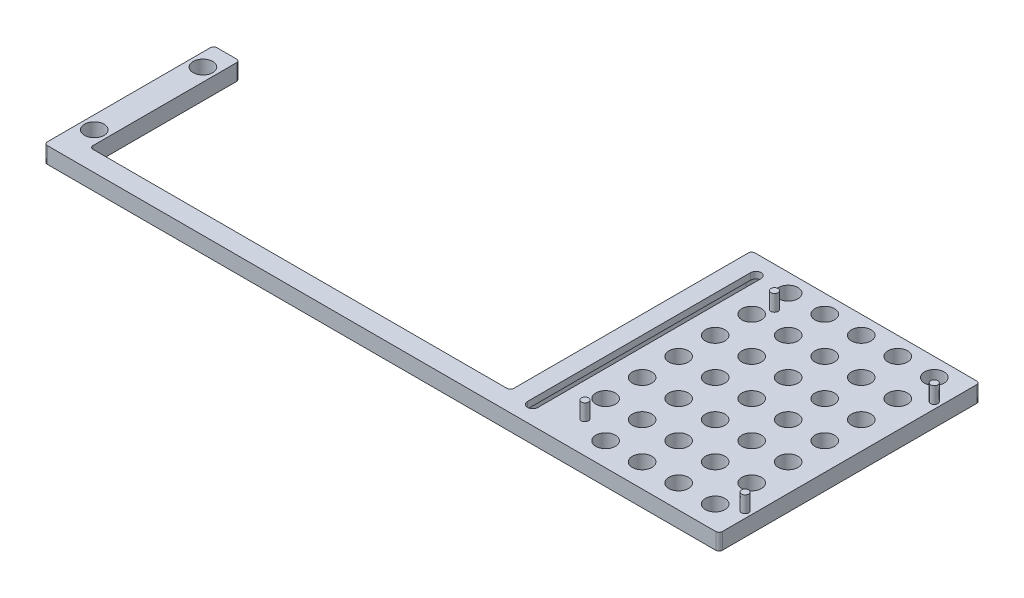
from build123d import *

# Parameters (mm, degrees)
SKETCH1_R           = 3
BOSS_EXTRUDE2_DEPTH = 5
SKETCH2_R           = 1.1
BOSS_EXTRUDE3_DEPTH = 5
FILLET1_R           = 1
CUT_EXTRUDE1_DEPTH  = 3


with BuildPart() as part:
    # Sketch1 → Boss-Extrude2 (new body)
    with BuildSketch(Plane(origin=(0, 0, 0), x_dir=(1, 0, 0), z_dir=(0, 1, 0))):
        Polygon((-35, 40), (35, 40), (35, -40), (-35, -40), (-172, -40), (-172, -34), (-172, 12), (-164, 12), (-164, -34), (-35, -34), align=None)
        with Locations((-18.2, 34.4)):
            Circle(SKETCH1_R, mode=Mode.SUBTRACT)
        with Locations((-7, 34.4)):
            Circle(SKETCH1_R, mode=Mode.SUBTRACT)
        with Locations((4.2, 34.4)):
            Circle(SKETCH1_R, mode=Mode.SUBTRACT)
        with Locations((15.4, 34.4)):
            Circle(SKETCH1_R, mode=Mode.SUBTRACT)
        with Locations((26.6, 34.4)):
            Circle(SKETCH1_R, mode=Mode.SUBTRACT)
        with Locations((-18.2, 23.2)):
            Circle(SKETCH1_R, mode=Mode.SUBTRACT)
        with Locations((-7, 23.2)):
            Circle(SKETCH1_R, mode=Mode.SUBTRACT)
        with Locations((4.2, 23.2)):
            Circle(SKETCH1_R, mode=Mode.SUBTRACT)
        with Locations((15.4, 23.2)):
            Circle(SKETCH1_R, mode=Mode.SUBTRACT)
        with Locations((26.6, 23.2)):
            Circle(SKETCH1_R, mode=Mode.SUBTRACT)
        with Locations((-18.2, 12)):
            Circle(SKETCH1_R, mode=Mode.SUBTRACT)
        with Locations((-7, 12)):
            Circle(SKETCH1_R, mode=Mode.SUBTRACT)
        with Locations((4.2, 12)):
            Circle(SKETCH1_R, mode=Mode.SUBTRACT)
        with Locations((15.4, 12)):
            Circle(SKETCH1_R, mode=Mode.SUBTRACT)
        with Locations((26.6, 12)):
            Circle(SKETCH1_R, mode=Mode.SUBTRACT)
        with Locations((-18.2, 0.8)):
            Circle(SKETCH1_R, mode=Mode.SUBTRACT)
        with Locations((-7, 0.8)):
            Circle(SKETCH1_R, mode=Mode.SUBTRACT)
        with Locations((4.2, 0.8)):
            Circle(SKETCH1_R, mode=Mode.SUBTRACT)
        with Locations((15.4, 0.8)):
            Circle(SKETCH1_R, mode=Mode.SUBTRACT)
        with Locations((26.6, 0.8)):
            Circle(SKETCH1_R, mode=Mode.SUBTRACT)
        with Locations((-18.2, -10.4)):
            Circle(SKETCH1_R, mode=Mode.SUBTRACT)
        with Locations((-7, -10.4)):
            Circle(SKETCH1_R, mode=Mode.SUBTRACT)
        with Locations((4.2, -10.4)):
            Circle(SKETCH1_R, mode=Mode.SUBTRACT)
        with Locations((15.4, -10.4)):
            Circle(SKETCH1_R, mode=Mode.SUBTRACT)
        with Locations((26.6, -10.4)):
            Circle(SKETCH1_R, mode=Mode.SUBTRACT)
        with Locations((-18.2, -21.6)):
            Circle(SKETCH1_R, mode=Mode.SUBTRACT)
        with Locations((-7, -21.6)):
            Circle(SKETCH1_R, mode=Mode.SUBTRACT)
        with Locations((4.2, -21.6)):
            Circle(SKETCH1_R, mode=Mode.SUBTRACT)
        with Locations((15.4, -21.6)):
            Circle(SKETCH1_R, mode=Mode.SUBTRACT)
        with Locations((26.6, -21.6)):
            Circle(SKETCH1_R, mode=Mode.SUBTRACT)
        with Locations((-7, -32.8)):
            Circle(SKETCH1_R, mode=Mode.SUBTRACT)
        with Locations((4.2, -32.8)):
            Circle(SKETCH1_R, mode=Mode.SUBTRACT)
        with Locations((15.4, -32.8)):
            Circle(SKETCH1_R, mode=Mode.SUBTRACT)
        with Locations((26.6, -32.8)):
            Circle(SKETCH1_R, mode=Mode.SUBTRACT)
        with Locations((-168, 4.718835642)):
            Circle(SKETCH1_R, mode=Mode.SUBTRACT)
        with Locations((-168, -28.604223743)):
            Circle(SKETCH1_R, mode=Mode.SUBTRACT)
        with BuildLine():
            Line((-26.219397272, 34.096793065), (-26.219397272, -34.303206935))
            ThreePointArc((-26.219397272, -34.303206935), (-27.819397272, -35.903206935), (-29.419397272, -34.303206935))
            Line((-29.419397272, -34.303206935), (-29.419397272, 34.096793065))
            ThreePointArc((-29.419397272, 34.096793065), (-27.819397272, 35.696793065), (-26.219397272, 34.096793065))
        make_face(mode=Mode.SUBTRACT)
    extrude(amount=BOSS_EXTRUDE2_DEPTH)

    # Sketch2 → Boss-Extrude3 (add)
    with BuildSketch(Plane(origin=(0, 5, 0), x_dir=(1, 0, 0), z_dir=(0, 1, 0))):
        with Locations((33, -30)):
            Circle(SKETCH2_R)
        with Locations((-15.999841725, -30.124542974)):
            Circle(SKETCH2_R)
        with Locations((-15.999841725, 28)):
            Circle(SKETCH2_R)
        with Locations((33, 28)):
            Circle(SKETCH2_R)
    extrude(amount=BOSS_EXTRUDE3_DEPTH)

    # Fillet1
    fillet1_edges = [part.edges().sort_by_distance(p)[0] for p in [
        (35, 2.5, 40),
        (-172, 2.5, 40),
        (-172, 2.5, -12),
        (-164, 2.5, -12),
        (-164, 2.5, 34),
        (-35, 2.5, 34),
        (-35, 2.5, -40),
        (35, 2.5, -40),
    ]]
    fillet(fillet1_edges, radius=FILLET1_R)

    # Sketch5 → Cut-Extrude1 (cut)
    with BuildSketch(Plane.XZ):
        with BuildLine():
            Line((-25.069397272, 34.303206935), (-25.069397272, -33.841459302))
            ThreePointArc((-25.069397272, -33.841459302), (-27.819397272, -36.591459302), (-30.569397272, -33.841459302))
            Line((-30.569397272, -33.841459302), (-30.569397272, 34.303206935))
            ThreePointArc((-30.569397272, 34.303206935), (-27.819397272, 37.053206935), (-25.069397272, 34.303206935))
        make_face()
    extrude(amount=-CUT_EXTRUDE1_DEPTH, mode=Mode.SUBTRACT)


solid = part.part
